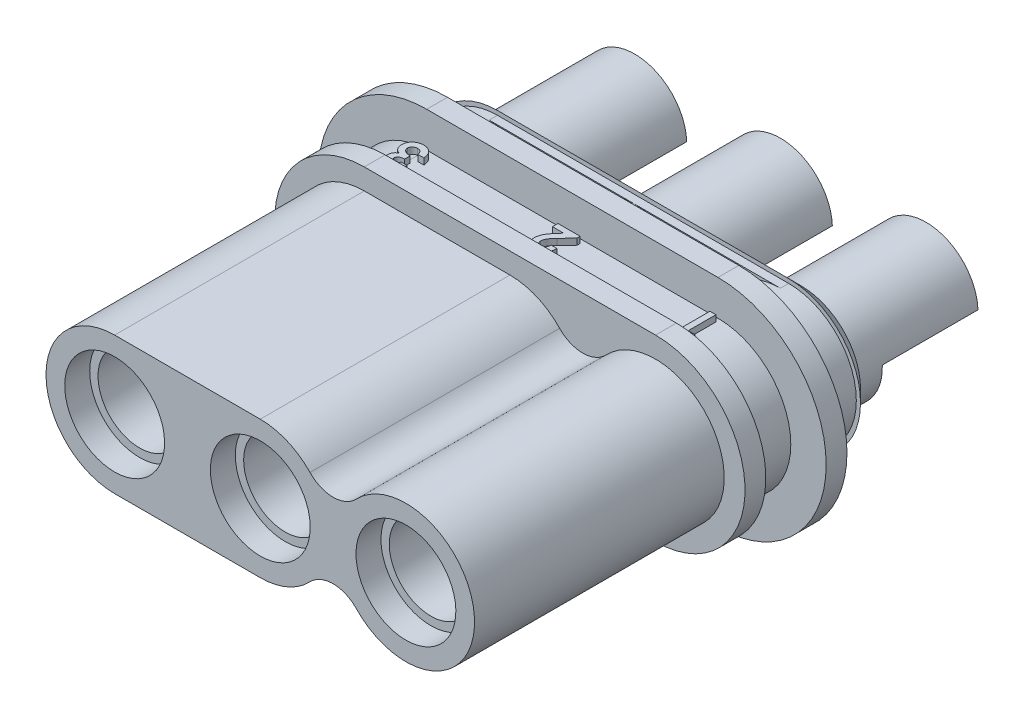
from build123d import *

# Parameters (mm, degrees)
BOSS_EXTRUDE1_DEPTH      = 6
CUT_EXTRUDE7_DEPTH       = 7
BOSS_EXTRUDE14_DEPTH     = 0.5
BOSS_EXTRUDE15_DEPTH     = 1
BOSS_EXTRUDE16_DEPTH     = 0.5
BOSS_EXTRUDE17_DEPTH     = 1.5
CHAMFER2_SIZE            = 0.3
CUT_EXTRUDE9_DEPTH       = 1.2
CUT_EXTRUDE11_DEPTH      = 1
MIRROR5_COPY_1_DEPTH     = 1
LPATTERN4_COUNT          = 3
LPATTERN4_PITCH          = 3.5
SKETCH33_W               = 2.3
SKETCH33_H               = 1.3
CUT_EXTRUDE10_DEPTH      = 7.1
CUT_EXTRUDE10_DEPTH_BACK = 7.1
LPATTERN5_COUNT          = 3
LPATTERN5_PITCH          = 3.5
BOSS_EXTRUDE18_DEPTH     = 0.3
BOSS_EXTRUDE19_DEPTH     = 0.3


with BuildPart() as part:
    # Sketch1 → Boss-Extrude1 (new body)
    with BuildSketch(Plane.XY):
        with BuildLine():
            Line((-3.5, 1.65), (3.5, 1.65))
            ThreePointArc((3.5, 1.65), (5.15, 0), (3.5, -1.65))
            Line((3.5, -1.65), (-3.5, -1.65))
            ThreePointArc((-3.5, -1.65), (-5.15, 0), (-3.5, 1.65))
        make_face()
    extrude(amount=BOSS_EXTRUDE1_DEPTH)

    # Sketch3 → Cut-Extrude7 (cut, through all)
    with BuildSketch(Plane.XY.offset(6)):
        with BuildLine():
            Line((3.5, 1.65), (0, 1.65))
            ThreePointArc((0, 1.65), (0.649966843, 1.5165893), (1.194827586, 1.137931034))
            ThreePointArc((1.194827586, 1.137931034), (1.75, 0.9), (2.305172414, 1.137931034))
            ThreePointArc((2.305172414, 1.137931034), (2.850033157, 1.5165893), (3.5, 1.65))
        make_face()
        with BuildLine():
            Line((3.5, -1.65), (0, -1.65))
            ThreePointArc((0, -1.65), (0.649966843, -1.5165893), (1.194827586, -1.137931034))
            ThreePointArc((1.194827586, -1.137931034), (1.75, -0.9), (2.305172414, -1.137931034))
            ThreePointArc((2.305172414, -1.137931034), (2.850033157, -1.5165893), (3.5, -1.65))
        make_face()
    extrude(amount=-CUT_EXTRUDE7_DEPTH, mode=Mode.SUBTRACT)

    # Sketch25 → Boss-Extrude14 (add)
    with BuildSketch(Plane(origin=(0, 0, 0), x_dir=(-1, 0, 0), z_dir=(0, 0, -1))):
        with BuildLine():
            Line((-3.5, 2.15), (3.5, 2.15))
            ThreePointArc((3.5, 2.15), (5.65, 0), (3.5, -2.15))
            Line((3.5, -2.15), (-3.5, -2.15))
            ThreePointArc((-3.5, -2.15), (-5.65, 0), (-3.5, 2.15))
        make_face()
    extrude(amount=BOSS_EXTRUDE14_DEPTH)

    # Sketch26 → Boss-Extrude15 (add)
    with BuildSketch(Plane(origin=(0, 0, -0.5), x_dir=(-1, 0, 0), z_dir=(0, 0, -1))):
        with BuildLine():
            Line((-3.5, 1.75), (3.5, 1.75))
            ThreePointArc((3.5, 1.75), (5.25, 0), (3.5, -1.75))
            Line((3.5, -1.75), (-3.5, -1.75))
            ThreePointArc((-3.5, -1.75), (-5.25, 0), (-3.5, 1.75))
        make_face()
    extrude(amount=BOSS_EXTRUDE15_DEPTH)

    # Sketch27 → Boss-Extrude16 (add)
    with BuildSketch(Plane(origin=(0, 0, -1.5), x_dir=(-1, 0, 0), z_dir=(0, 0, -1))):
        with BuildLine():
            Line((-3.5, 2.6), (3.5, 2.6))
            ThreePointArc((3.5, 2.6), (6.1, 0), (3.5, -2.6))
            Line((3.5, -2.6), (-3.5, -2.6))
            ThreePointArc((-3.5, -2.6), (-6.1, 0), (-3.5, 2.6))
        make_face()
    extrude(amount=BOSS_EXTRUDE16_DEPTH)

    # Sketch28 → Boss-Extrude17 (add)
    with BuildSketch(Plane(origin=(0, 0, -2), x_dir=(-1, 0, 0), z_dir=(0, 0, -1))):
        with BuildLine():
            Line((-3.5, 1.725), (3.5, 1.725))
            ThreePointArc((3.5, 1.725), (5.225, 0), (3.5, -1.725))
            Line((3.5, -1.725), (-3.5, -1.725))
            ThreePointArc((-3.5, -1.725), (-5.225, 0), (-3.5, 1.725))
        make_face()
    extrude(amount=BOSS_EXTRUDE17_DEPTH)

    # Chamfer2
    chamfer2_edges = [part.edges().sort_by_distance(p)[0] for p in [
        (5.225, 0, -3.5),
        (0, -1.725, -3.5),
        (-5.225, 0, -3.5),
        (0, 1.725, -3.5),
    ]]
    chamfer(chamfer2_edges, length=CHAMFER2_SIZE)

    # Sketch29 → Cut-Extrude9 (cut)
    with BuildSketch(Plane(origin=(0, 0, -2), x_dir=(-1, 0, 0), z_dir=(0, 0, -1))):
        with BuildLine():
            Line((3.5, 1.725), (-3.5, 1.725))
            ThreePointArc((-3.5, 1.725), (-5.225, 0), (-3.5, -1.725))
            Line((-3.5, -1.725), (3.5, -1.725))
            ThreePointArc((3.5, -1.725), (5.225, 0), (3.5, 1.725))
        make_face()
        with BuildLine():
            Line((3.5, 1.625), (-3.5, 1.625))
            ThreePointArc((-3.5, 1.625), (-5.125, 0), (-3.5, -1.625))
            Line((-3.5, -1.625), (3.5, -1.625))
            ThreePointArc((3.5, -1.625), (5.125, 0), (3.5, 1.625))
        make_face(mode=Mode.SUBTRACT)
    extrude(amount=CUT_EXTRUDE9_DEPTH, mode=Mode.SUBTRACT)

    # Sketch35 → Cut-Extrude11 (cut)
    with BuildSketch(Plane(origin=(0, 0, -2), x_dir=(-1, 0, 0), z_dir=(0, 0, -1))):
        with BuildLine():
            Line((3.5, 1.625), (3.5, 2.6))
            Line((3.5, 2.6), (0, 2.6))
            Line((0, 2.6), (0, 1.625))
            ThreePointArc((0, 1.625), (0.692931252, 1.46985417), (1.253548172, 1.034041576))
            ThreePointArc((1.253548172, 1.034041576), (1.75, 0.8), (2.246451828, 1.034041576))
            ThreePointArc((2.246451828, 1.034041576), (2.807068748, 1.46985417), (3.5, 1.625))
        make_face()
    cut_extrude11 = extrude(amount=CUT_EXTRUDE11_DEPTH, mode=Mode.SUBTRACT)

    # Mirror4: Cut-Extrude11 across plane
    add(cut_extrude11.mirror(Plane(origin=(0, 0, 0), x_dir=(0, 0, 1), z_dir=(1, 0, 0))), mode=Mode.SUBTRACT)

    # Mirror5: Cut-Extrude11 across plane
    add(cut_extrude11.mirror(Plane.ZX), mode=Mode.SUBTRACT)

    # Mirror5 copy 1 sketch → Mirror5 copy 1 (cut)
    with BuildSketch(Plane(origin=(0, 0, -2), x_dir=(1, 0, 0), z_dir=(0, 0, -1))):
        with BuildLine():
            Line((3.5, 1.625), (3.5, 2.6))
            Line((3.5, 2.6), (0, 2.6))
            Line((0, 2.6), (0, 1.625))
            ThreePointArc((0, 1.625), (0.692931252, 1.46985417), (1.253548172, 1.034041576))
            ThreePointArc((1.253548172, 1.034041576), (1.75, 0.8), (2.246451828, 1.034041576))
            ThreePointArc((2.246451828, 1.034041576), (2.807068748, 1.46985417), (3.5, 1.625))
        make_face()
    extrude(amount=MIRROR5_COPY_1_DEPTH, mode=Mode.SUBTRACT)

    # Sketch31 → Cut-Revolve1 (revolve, cut)
    with BuildSketch(Plane(origin=(3.5, 0, 0), x_dir=(0, 0, -1), z_dir=(1, 0, 0))):
        Polygon((-6, 0), (-6, 1.2), (0.5, 1.2), (0.5, 1.25), (3.5, 1.25), (3.5, 0), align=None)
    cut_revolve1 = revolve(axis=Axis((3.5, 0, 6), (0, 0, -1)), mode=Mode.SUBTRACT)

    # LPattern4: Cut-Revolve1 ×3
    with Locations(*[(-i * LPATTERN4_PITCH, 0, 0) for i in range(1, LPATTERN4_COUNT)]):
        add(cut_revolve1, mode=Mode.SUBTRACT)

    # Sketch38 → Boss-Extrude18 (add)
    with BuildSketch(Plane(origin=(0, 1.9, 0), x_dir=(1, 0, 0), z_dir=(0, 1, 0))):
        Polygon((3.629647436, 0.6), (3.407692308, 0.6), (3.407692308, 1.4), (3.551282051, 1.4), (3.551282051, 0.733333333), (3.715384615, 0.733333333), align=None)
        with BuildLine():
            Line((0.123076923, 0.866666667), (0.266666667, 0.866666667))
            add(Edge.make_bspline(
                [(0.266666667, 0.866666667), (0.266046768, 0.855804749), (0.264835523, 0.834581213), (0.260012214, 0.803755254), (0.253565751, 0.774620985), (0.244888653, 0.747265996), (0.234200861, 0.721678794), (0.221236367, 0.697944135), (0.206382245, 0.675891949), (0.189339082, 0.655908987), (0.170798578, 0.637943697), (0.150808265, 0.622237969), (0.129424927, 0.609090221), (0.10679155, 0.598305063), (0.082997035, 0.589675548), (0.057800973, 0.583909056), (0.031425685, 0.580003086), (0.013369504, 0.579661353), (0.004166667, 0.579487179)],
                knots=[0, 0, 0, 0, 3.2621e-05, 6.3739e-05, 9.348e-05, 0.000122065, 0.000149716, 0.000176536, 0.000203072, 0.000229337, 0.000255178, 0.000280407, 0.000305447, 0.000330319, 0.000355512, 0.000381206, 0.000407745, 0.000435332, 0.000435332, 0.000435332, 0.000435332], degree=3))
            add(Edge.make_bspline(
                [(0.004166667, 0.579487179), (-0.00713451, 0.579816538), (-0.029206749, 0.580459807), (-0.061177039, 0.586653296), (-0.091225249, 0.596193698), (-0.119054441, 0.60991552), (-0.144518759, 0.627297778), (-0.167315487, 0.648245635), (-0.187549249, 0.672502137), (-0.204553009, 0.699889992), (-0.218383227, 0.728992028), (-0.22836896, 0.758908731), (-0.234854856, 0.789036897), (-0.235551403, 0.809316467), (-0.235897436, 0.819391026)],
                knots=[0, 0, 0, 0, 3.3869e-05, 6.6149e-05, 9.7316e-05, 0.000128207, 0.000158877, 0.000189503, 0.000220794, 0.000253342, 0.000285959, 0.000317227, 0.000347807, 0.000377997, 0.000377997, 0.000377997, 0.000377997], degree=3))
            add(Edge.make_bspline(
                [(-0.235897436, 0.819391026), (-0.235763219, 0.825485184), (-0.235493074, 0.837751219), (-0.23361472, 0.85631274), (-0.230796817, 0.87521982), (-0.226548105, 0.894456247), (-0.221249619, 0.914027416), (-0.214821768, 0.933991881), (-0.20711555, 0.954236517), (-0.198259186, 0.974988912), (-0.187694797, 0.99631749), (-0.175388785, 1.018537648), (-0.161001588, 1.041710528), (-0.144673668, 1.065763984), (-0.126520041, 1.090884558), (-0.106264392, 1.116774734), (-0.084166144, 1.14372681), (-0.068477229, 1.161739256), (-0.060416667, 1.17099359)],
                knots=[0, 0, 0, 0, 1.828e-05, 3.6794e-05, 5.5923e-05, 7.56e-05, 9.5854e-05, 0.000116734, 0.000138492, 0.000160818, 0.000184398, 0.000209863, 0.000236992, 0.000266194, 0.000297064, 0.000329953, 0.000364795, 0.000401611, 0.000401611, 0.000401611, 0.000401611], degree=3))
            Line((-0.060416667, 1.17099359), (0.023076923, 1.266666667))
            Line((0.023076923, 1.266666667), (-0.246153846, 1.266666667))
            Line((-0.246153846, 1.266666667), (-0.246153846, 1.4))
            Line((-0.246153846, 1.4), (0.287179487, 1.4))
            Line((0.287179487, 1.4), (0.287179487, 1.32724359))
            Line((0.287179487, 1.32724359), (0.050320513, 1.075160256))
            add(Edge.make_bspline(
                [(0.050320513, 1.075160256), (0.043462728, 1.06780698), (0.030181233, 1.053565866), (0.011284798, 1.032650078), (-0.005821099, 1.01280578), (-0.020753974, 0.993802842), (-0.034417307, 0.97628468), (-0.045847691, 0.959589039), (-0.055802154, 0.944186098), (-0.066200643, 0.925410527), (-0.07630305, 0.903186446), (-0.085566796, 0.877599219), (-0.091157085, 0.853126573), (-0.091934663, 0.837151121), (-0.092307692, 0.829487179)],
                knots=[0, 0, 0, 0, 3.0164e-05, 5.8419e-05, 8.4562e-05, 0.000108739, 0.000130919, 0.00015119, 0.000169418, 0.000185917, 0.000215533, 0.000242548, 0.000267475, 0.000290459, 0.000290459, 0.000290459, 0.000290459], degree=3))
            add(Edge.make_bspline(
                [(-0.092307692, 0.829487179), (-0.092033867, 0.822070436), (-0.091503287, 0.807699307), (-0.085527303, 0.787315926), (-0.076585755, 0.768720806), (-0.063604322, 0.752761006), (-0.047936064, 0.739531817), (-0.029726945, 0.729837626), (-0.009311298, 0.724139891), (0.004985166, 0.723437999), (0.012339744, 0.723076923)],
                knots=[0, 0, 0, 0, 2.2186e-05, 4.2988e-05, 6.3199e-05, 8.3722e-05, 0.000104199, 0.000124345, 0.000145147, 0.000167186, 0.000167186, 0.000167186, 0.000167186], degree=3))
            add(Edge.make_bspline(
                [(0.012339744, 0.723076923), (0.016138463, 0.723211282), (0.023616852, 0.723475789), (0.034609499, 0.72523654), (0.045069793, 0.728339679), (0.055114162, 0.73249745), (0.06463541, 0.738008604), (0.073609521, 0.74480198), (0.08213105, 0.752704942), (0.090160913, 0.761692779), (0.097469136, 0.771723208), (0.103960273, 0.78270462), (0.109327363, 0.794630201), (0.114052744, 0.807342514), (0.117697184, 0.820978099), (0.120350788, 0.835455349), (0.122368146, 0.850750712), (0.122836366, 0.861264835), (0.123076923, 0.866666667)],
                knots=[0, 0, 0, 0, 1.1396e-05, 2.2435e-05, 3.3288e-05, 4.4062e-05, 5.4975e-05, 6.6193e-05, 7.776e-05, 8.9791e-05, 0.000102292, 0.000114935, 0.000127986, 0.000141472, 0.000155584, 0.000170262, 0.000185607, 0.000201822, 0.000201822, 0.000201822, 0.000201822], degree=3))
        make_face()
        with BuildLine():
            Line((-3.407692308, 0.794871795), (-3.264102564, 0.794871795))
            add(Edge.make_bspline(
                [(-3.264102564, 0.794871795), (-3.265110038, 0.787692685), (-3.267077884, 0.773670107), (-3.27191539, 0.753320344), (-3.277509672, 0.73396922), (-3.284663968, 0.715720587), (-3.292922312, 0.698594117), (-3.302552662, 0.682574484), (-3.313108163, 0.667431794), (-3.321372461, 0.658357249), (-3.325480769, 0.653846154)],
                knots=[0, 0, 0, 0, 2.1736e-05, 4.2457e-05, 6.2688e-05, 8.2121e-05, 0.000101186, 0.000119655, 0.000138154, 0.000156441, 0.000156441, 0.000156441, 0.000156441], degree=3))
            add(Edge.make_bspline(
                [(-3.325480769, 0.653846154), (-3.331391845, 0.647884889), (-3.343041954, 0.636135864), (-3.362510653, 0.621086659), (-3.382917445, 0.608062597), (-3.404671597, 0.597737025), (-3.427434599, 0.589379672), (-3.451387468, 0.583766018), (-3.476432326, 0.58004131), (-3.493522291, 0.579674413), (-3.50224359, 0.579487179)],
                knots=[0, 0, 0, 0, 2.5161e-05, 4.9589e-05, 7.3643e-05, 9.7655e-05, 0.000121684, 0.000146249, 0.000171338, 0.000197484, 0.000197484, 0.000197484, 0.000197484], degree=3))
            add(Edge.make_bspline(
                [(-3.50224359, 0.579487179), (-3.509997273, 0.579670229), (-3.525239452, 0.580030067), (-3.54764162, 0.582918651), (-3.569000212, 0.587984905), (-3.589540995, 0.59460892), (-3.608961881, 0.603621998), (-3.627691508, 0.614084264), (-3.645206569, 0.626916668), (-3.661548047, 0.641415992), (-3.676560811, 0.657098432), (-3.68956193, 0.673861669), (-3.700739225, 0.691257921), (-3.709947838, 0.709431716), (-3.717028011, 0.728413808), (-3.72194186, 0.748094539), (-3.725158094, 0.768430481), (-3.725478515, 0.782252548), (-3.725641026, 0.789262821)],
                knots=[0, 0, 0, 0, 2.3257e-05, 4.5719e-05, 6.7604e-05, 8.9041e-05, 0.000110341, 0.000131729, 0.000153302, 0.000175328, 0.000197206, 0.000218331, 0.00023887, 0.000259152, 0.000279334, 0.000299507, 0.000319928, 0.000340943, 0.000340943, 0.000340943, 0.000340943], degree=3))
            add(Edge.make_bspline(
                [(-3.725641026, 0.789262821), (-3.725301122, 0.797942918), (-3.724629907, 0.815083709), (-3.719321582, 0.840121172), (-3.710788146, 0.86400708), (-3.698654865, 0.886458422), (-3.683418114, 0.907451808), (-3.664733127, 0.926254035), (-3.643121327, 0.943156287), (-3.626897512, 0.952239674), (-3.618589744, 0.956891026)],
                knots=[0, 0, 0, 0, 2.6021e-05, 5.1385e-05, 7.6427e-05, 0.00010188, 0.000127683, 0.000153974, 0.000181157, 0.000209685, 0.000209685, 0.000209685, 0.000209685], degree=3))
            add(Edge.make_bspline(
                [(-3.618589744, 0.956891026), (-3.624292282, 0.95876298), (-3.635497514, 0.962441288), (-3.651421192, 0.969690146), (-3.666575254, 0.977595115), (-3.680613131, 0.98682332), (-3.693919779, 0.996735132), (-3.706074192, 1.007863481), (-3.717391107, 1.019922719), (-3.727590556, 1.033041134), (-3.736709336, 1.047000613), (-3.744745628, 1.061550257), (-3.751489587, 1.076743241), (-3.757149758, 1.092467918), (-3.761468312, 1.108879044), (-3.764506571, 1.125921006), (-3.766263332, 1.143552739), (-3.766531215, 1.15549831), (-3.766666667, 1.161538462)],
                knots=[0, 0, 0, 0, 1.7992e-05, 3.5354e-05, 5.2417e-05, 6.9219e-05, 8.5694e-05, 0.000102144, 0.000118585, 0.000135255, 0.000151923, 0.000168563, 0.000185062, 0.000201739, 0.000218648, 0.000235906, 0.000253622, 0.000271742, 0.000271742, 0.000271742, 0.000271742], degree=3))
            add(Edge.make_bspline(
                [(-3.766666667, 1.161538462), (-3.766415585, 1.170418926), (-3.765920292, 1.187936833), (-3.762139581, 1.213654894), (-3.756067127, 1.238306774), (-3.747535492, 1.261923544), (-3.736364904, 1.284434281), (-3.722873121, 1.305990358), (-3.706895308, 1.326422392), (-3.688673719, 1.345549362), (-3.668607444, 1.363102462), (-3.646991124, 1.378595763), (-3.623811188, 1.391371324), (-3.599620552, 1.402290041), (-3.573876266, 1.410393698), (-3.546910808, 1.416328048), (-3.518527417, 1.419938703), (-3.499155961, 1.420318735), (-3.489262821, 1.420512821)],
                knots=[0, 0, 0, 0, 2.6633e-05, 5.2538e-05, 7.7802e-05, 0.000102694, 0.000127706, 0.000153051, 0.000178857, 0.000205382, 0.000232187, 0.000258734, 0.000284993, 0.000311467, 0.000338226, 0.000365794, 0.000394219, 0.000423888, 0.000423888, 0.000423888, 0.000423888], degree=3))
            add(Edge.make_bspline(
                [(-3.489262821, 1.420512821), (-3.47990384, 1.420308711), (-3.461603591, 1.419909602), (-3.434836164, 1.416453481), (-3.4093943, 1.410882333), (-3.385222195, 1.403015976), (-3.362422759, 1.392881034), (-3.340863165, 1.38064799), (-3.320778775, 1.365942023), (-3.302077124, 1.349110101), (-3.284916761, 1.330485787), (-3.269960833, 1.309917271), (-3.256945234, 1.287853995), (-3.245784062, 1.26424851), (-3.237063597, 1.238890193), (-3.230128443, 1.212005501), (-3.225300187, 1.183478185), (-3.223827688, 1.163852473), (-3.223076923, 1.153846154)],
                knots=[0, 0, 0, 0, 2.8067e-05, 5.4882e-05, 8.0816e-05, 0.000106105, 0.000131, 0.000155549, 0.000180327, 0.00020552, 0.000230929, 0.000256155, 0.00028166, 0.000307684, 0.000334344, 0.000361979, 0.000390907, 0.000420999, 0.000420999, 0.000420999, 0.000420999], degree=3))
            Line((-3.223076923, 1.153846154), (-3.366666667, 1.153846154))
            add(Edge.make_bspline(
                [(-3.366666667, 1.153846154), (-3.367576757, 1.158877451), (-3.369349398, 1.168677223), (-3.372803698, 1.182866509), (-3.377316971, 1.195958941), (-3.382476982, 1.208050709), (-3.38818198, 1.219265904), (-3.394998463, 1.229304614), (-3.402307246, 1.238561359), (-3.413294012, 1.249201364), (-3.428623067, 1.260359659), (-3.449377705, 1.270241956), (-3.472570598, 1.27586239), (-3.488751847, 1.276561652), (-3.497115385, 1.276923077)],
                knots=[0, 0, 0, 0, 1.5338e-05, 2.9874e-05, 4.376e-05, 5.6828e-05, 6.93e-05, 8.1434e-05, 9.3172e-05, 0.000104618, 0.000127217, 0.000149726, 0.000173164, 0.000198237, 0.000198237, 0.000198237, 0.000198237], degree=3))
            add(Edge.make_bspline(
                [(-3.497115385, 1.276923077), (-3.501554056, 1.276846697), (-3.510248421, 1.276697087), (-3.523021245, 1.27504823), (-3.535181139, 1.272312985), (-3.54685512, 1.268641539), (-3.557883958, 1.263800065), (-3.568408651, 1.258042591), (-3.578241926, 1.251043346), (-3.587414758, 1.243150693), (-3.595716249, 1.234459495), (-3.603224491, 1.225380966), (-3.609250591, 1.215544148), (-3.614252745, 1.205338059), (-3.61837892, 1.194765335), (-3.620967673, 1.183585416), (-3.622905828, 1.172022385), (-3.623019322, 1.164111229), (-3.623076923, 1.160096154)],
                knots=[0, 0, 0, 0, 1.331e-05, 2.6071e-05, 3.8552e-05, 5.0665e-05, 6.2722e-05, 7.463e-05, 8.659e-05, 9.8862e-05, 0.000110876, 0.000122614, 0.000134131, 0.000145384, 0.000156694, 0.000168082, 0.000179755, 0.000191783, 0.000191783, 0.000191783, 0.000191783], degree=3))
            add(Edge.make_bspline(
                [(-3.623076923, 1.160096154), (-3.62293067, 1.155703491), (-3.622641263, 1.14701125), (-3.620094498, 1.134273186), (-3.616282366, 1.121972746), (-3.610799812, 1.110211417), (-3.603625646, 1.099058371), (-3.594902596, 1.088421236), (-3.584551752, 1.078384702), (-3.572919734, 1.068656464), (-3.559537212, 1.06014041), (-3.544944592, 1.052298399), (-3.528782374, 1.046054224), (-3.511438291, 1.040478382), (-3.492586234, 1.036405534), (-3.472342699, 1.033448348), (-3.450740506, 1.031247152), (-3.435849827, 1.030931356), (-3.428205128, 1.030769231)],
                knots=[0, 0, 0, 0, 1.3165e-05, 2.6052e-05, 3.8824e-05, 5.173e-05, 6.4844e-05, 7.851e-05, 9.2902e-05, 0.000108045, 0.000123914, 0.000140402, 0.000157662, 0.000175807, 0.000195014, 0.000215435, 0.00023717, 0.0002601, 0.0002601, 0.0002601, 0.0002601], degree=3))
            Line((-3.428205128, 1.030769231), (-3.428205128, 0.897435897))
            add(Edge.make_bspline(
                [(-3.428205128, 0.897435897), (-3.437724188, 0.89662759), (-3.455532462, 0.895115408), (-3.480237317, 0.891541593), (-3.501146182, 0.886868989), (-3.518483817, 0.88088338), (-3.533095555, 0.873858931), (-3.545535092, 0.865525082), (-3.556609378, 0.856297296), (-3.565650741, 0.84569821), (-3.572956996, 0.834509718), (-3.578130362, 0.822762631), (-3.581564502, 0.810718096), (-3.581889998, 0.802479613), (-3.582051282, 0.798397436)],
                knots=[0, 0, 0, 0, 2.8655e-05, 5.3609e-05, 7.4833e-05, 9.2826e-05, 0.000108522, 0.000123323, 0.000137646, 0.000151621, 0.000164957, 0.000177584, 0.000190023, 0.000202241, 0.000202241, 0.000202241, 0.000202241], degree=3))
            add(Edge.make_bspline(
                [(-3.582051282, 0.798397436), (-3.581779439, 0.793185696), (-3.58124886, 0.783013483), (-3.576936579, 0.768490819), (-3.569930338, 0.755330384), (-3.560065735, 0.743985882), (-3.54799617, 0.734619235), (-3.533935683, 0.727792187), (-3.518122667, 0.723708571), (-3.507022724, 0.723292241), (-3.501282051, 0.723076923)],
                knots=[0, 0, 0, 0, 1.5612e-05, 3.0471e-05, 4.5026e-05, 6.0027e-05, 7.5221e-05, 9.0558e-05, 0.000106611, 0.000123807, 0.000123807, 0.000123807, 0.000123807], degree=3))
            add(Edge.make_bspline(
                [(-3.501282051, 0.723076923), (-3.49607903, 0.723332439), (-3.485754643, 0.723839461), (-3.470663393, 0.727640582), (-3.456348242, 0.733974611), (-3.443176315, 0.742869387), (-3.431180006, 0.753441906), (-3.421121344, 0.765862082), (-3.412932971, 0.779644117), (-3.409446044, 0.789776003), (-3.407692308, 0.794871795)],
                knots=[0, 0, 0, 0, 1.5598e-05, 3.0951e-05, 4.6376e-05, 6.2333e-05, 7.8449e-05, 9.4167e-05, 0.00011011, 0.000126241, 0.000126241, 0.000126241, 0.000126241], degree=3))
        make_face()
    extrude(amount=-BOSS_EXTRUDE18_DEPTH)

    # Sketch39 → Boss-Extrude19 (add)
    with BuildSketch(Plane(origin=(0, -1.9, 0), x_dir=(-1, 0, 0), z_dir=(0, -1, 0))):
        with BuildLine():
            Line((3.592307692, 0.794871795), (3.735897436, 0.794871795))
            add(Edge.make_bspline(
                [(3.735897436, 0.794871795), (3.734889962, 0.787692685), (3.732922116, 0.773670107), (3.72808461, 0.753320344), (3.722490328, 0.73396922), (3.715336032, 0.715720587), (3.707077688, 0.698594117), (3.697447338, 0.682574484), (3.686891837, 0.667431794), (3.678627539, 0.658357249), (3.674519231, 0.653846154)],
                knots=[0, 0, 0, 0, 2.1736e-05, 4.2457e-05, 6.2688e-05, 8.2121e-05, 0.000101186, 0.000119655, 0.000138154, 0.000156441, 0.000156441, 0.000156441, 0.000156441], degree=3))
            add(Edge.make_bspline(
                [(3.674519231, 0.653846154), (3.668608155, 0.647884889), (3.656958046, 0.636135864), (3.637489347, 0.621086659), (3.617082555, 0.608062597), (3.595328403, 0.597737025), (3.572565401, 0.589379672), (3.548612532, 0.583766018), (3.523567674, 0.58004131), (3.506477709, 0.579674413), (3.49775641, 0.579487179)],
                knots=[0, 0, 0, 0, 2.5161e-05, 4.9589e-05, 7.3643e-05, 9.7655e-05, 0.000121684, 0.000146249, 0.000171338, 0.000197484, 0.000197484, 0.000197484, 0.000197484], degree=3))
            add(Edge.make_bspline(
                [(3.49775641, 0.579487179), (3.490002727, 0.579670229), (3.474760548, 0.580030067), (3.45235838, 0.582918651), (3.430999788, 0.587984905), (3.410459005, 0.59460892), (3.391038119, 0.603621998), (3.372308492, 0.614084264), (3.354793431, 0.626916668), (3.338451953, 0.641415992), (3.323439189, 0.657098432), (3.31043807, 0.673861669), (3.299260775, 0.691257921), (3.290052162, 0.709431716), (3.282971989, 0.728413808), (3.27805814, 0.748094539), (3.274841906, 0.768430481), (3.274521485, 0.782252548), (3.274358974, 0.789262821)],
                knots=[0, 0, 0, 0, 2.3257e-05, 4.5719e-05, 6.7604e-05, 8.9041e-05, 0.000110341, 0.000131729, 0.000153302, 0.000175328, 0.000197206, 0.000218331, 0.00023887, 0.000259152, 0.000279334, 0.000299507, 0.000319928, 0.000340943, 0.000340943, 0.000340943, 0.000340943], degree=3))
            add(Edge.make_bspline(
                [(3.274358974, 0.789262821), (3.274698878, 0.797942918), (3.275370093, 0.815083709), (3.280678418, 0.840121172), (3.289211854, 0.86400708), (3.301345135, 0.886458422), (3.316581886, 0.907451808), (3.335266873, 0.926254035), (3.356878673, 0.943156287), (3.373102488, 0.952239674), (3.381410256, 0.956891026)],
                knots=[0, 0, 0, 0, 2.6021e-05, 5.1385e-05, 7.6427e-05, 0.00010188, 0.000127683, 0.000153974, 0.000181157, 0.000209685, 0.000209685, 0.000209685, 0.000209685], degree=3))
            add(Edge.make_bspline(
                [(3.381410256, 0.956891026), (3.375707718, 0.95876298), (3.364502486, 0.962441288), (3.348578808, 0.969690146), (3.333424746, 0.977595115), (3.319386869, 0.98682332), (3.306080221, 0.996735132), (3.293925808, 1.007863481), (3.282608893, 1.019922719), (3.272409444, 1.033041134), (3.263290664, 1.047000613), (3.255254372, 1.061550257), (3.248510413, 1.076743241), (3.242850242, 1.092467918), (3.238531688, 1.108879044), (3.235493429, 1.125921006), (3.233736668, 1.143552739), (3.233468785, 1.15549831), (3.233333333, 1.161538462)],
                knots=[0, 0, 0, 0, 1.7992e-05, 3.5354e-05, 5.2417e-05, 6.9219e-05, 8.5694e-05, 0.000102144, 0.000118585, 0.000135255, 0.000151923, 0.000168563, 0.000185062, 0.000201739, 0.000218648, 0.000235906, 0.000253622, 0.000271742, 0.000271742, 0.000271742, 0.000271742], degree=3))
            add(Edge.make_bspline(
                [(3.233333333, 1.161538462), (3.233584415, 1.170418926), (3.234079708, 1.187936833), (3.237860419, 1.213654894), (3.243932873, 1.238306774), (3.252464508, 1.261923544), (3.263635096, 1.284434281), (3.277126879, 1.305990358), (3.293104692, 1.326422392), (3.311326281, 1.345549362), (3.331392556, 1.363102462), (3.353008876, 1.378595763), (3.376188812, 1.391371324), (3.400379448, 1.402290041), (3.426123734, 1.410393698), (3.453089192, 1.416328048), (3.481472583, 1.419938703), (3.500844039, 1.420318735), (3.510737179, 1.420512821)],
                knots=[0, 0, 0, 0, 2.6633e-05, 5.2538e-05, 7.7802e-05, 0.000102694, 0.000127706, 0.000153051, 0.000178857, 0.000205382, 0.000232187, 0.000258734, 0.000284993, 0.000311467, 0.000338226, 0.000365794, 0.000394219, 0.000423888, 0.000423888, 0.000423888, 0.000423888], degree=3))
            add(Edge.make_bspline(
                [(3.510737179, 1.420512821), (3.52009616, 1.420308711), (3.538396409, 1.419909602), (3.565163836, 1.416453481), (3.5906057, 1.410882333), (3.614777805, 1.403015976), (3.637577241, 1.392881034), (3.659136835, 1.38064799), (3.679221225, 1.365942023), (3.697922876, 1.349110101), (3.715083239, 1.330485787), (3.730039167, 1.309917271), (3.743054766, 1.287853995), (3.754215938, 1.26424851), (3.762936403, 1.238890193), (3.769871557, 1.212005501), (3.774699813, 1.183478185), (3.776172312, 1.163852473), (3.776923077, 1.153846154)],
                knots=[0, 0, 0, 0, 2.8067e-05, 5.4882e-05, 8.0816e-05, 0.000106105, 0.000131, 0.000155549, 0.000180327, 0.00020552, 0.000230929, 0.000256155, 0.00028166, 0.000307684, 0.000334344, 0.000361979, 0.000390907, 0.000420999, 0.000420999, 0.000420999, 0.000420999], degree=3))
            Line((3.776923077, 1.153846154), (3.633333333, 1.153846154))
            add(Edge.make_bspline(
                [(3.633333333, 1.153846154), (3.632423243, 1.158877451), (3.630650602, 1.168677223), (3.627196302, 1.182866509), (3.622683029, 1.195958941), (3.617523018, 1.208050709), (3.61181802, 1.219265904), (3.605001537, 1.229304614), (3.597692754, 1.238561359), (3.586705988, 1.249201364), (3.571376933, 1.260359659), (3.550622295, 1.270241956), (3.527429402, 1.27586239), (3.511248153, 1.276561652), (3.502884615, 1.276923077)],
                knots=[0, 0, 0, 0, 1.5338e-05, 2.9874e-05, 4.376e-05, 5.6828e-05, 6.93e-05, 8.1434e-05, 9.3172e-05, 0.000104618, 0.000127217, 0.000149726, 0.000173164, 0.000198237, 0.000198237, 0.000198237, 0.000198237], degree=3))
            add(Edge.make_bspline(
                [(3.502884615, 1.276923077), (3.498445944, 1.276846697), (3.489751579, 1.276697087), (3.476978755, 1.27504823), (3.464818861, 1.272312985), (3.45314488, 1.268641539), (3.442116042, 1.263800065), (3.431591349, 1.258042591), (3.421758074, 1.251043346), (3.412585242, 1.243150693), (3.404283751, 1.234459495), (3.396775509, 1.225380966), (3.390749409, 1.215544148), (3.385747255, 1.205338059), (3.38162108, 1.194765335), (3.379032327, 1.183585416), (3.377094172, 1.172022385), (3.376980678, 1.164111229), (3.376923077, 1.160096154)],
                knots=[0, 0, 0, 0, 1.331e-05, 2.6071e-05, 3.8552e-05, 5.0665e-05, 6.2722e-05, 7.463e-05, 8.659e-05, 9.8862e-05, 0.000110876, 0.000122614, 0.000134131, 0.000145384, 0.000156694, 0.000168082, 0.000179755, 0.000191783, 0.000191783, 0.000191783, 0.000191783], degree=3))
            add(Edge.make_bspline(
                [(3.376923077, 1.160096154), (3.37706933, 1.155703491), (3.377358737, 1.14701125), (3.379905502, 1.134273186), (3.383717634, 1.121972746), (3.389200188, 1.110211417), (3.396374354, 1.099058371), (3.405097404, 1.088421236), (3.415448248, 1.078384702), (3.427080266, 1.068656464), (3.440462788, 1.06014041), (3.455055408, 1.052298399), (3.471217626, 1.046054224), (3.488561709, 1.040478382), (3.507413766, 1.036405534), (3.527657301, 1.033448348), (3.549259494, 1.031247152), (3.564150173, 1.030931356), (3.571794872, 1.030769231)],
                knots=[0, 0, 0, 0, 1.3165e-05, 2.6052e-05, 3.8824e-05, 5.173e-05, 6.4844e-05, 7.851e-05, 9.2902e-05, 0.000108045, 0.000123914, 0.000140402, 0.000157662, 0.000175807, 0.000195014, 0.000215435, 0.00023717, 0.0002601, 0.0002601, 0.0002601, 0.0002601], degree=3))
            Line((3.571794872, 1.030769231), (3.571794872, 0.897435897))
            add(Edge.make_bspline(
                [(3.571794872, 0.897435897), (3.562275812, 0.89662759), (3.544467538, 0.895115408), (3.519762683, 0.891541593), (3.498853818, 0.886868989), (3.481516183, 0.88088338), (3.466904445, 0.873858931), (3.454464908, 0.865525082), (3.443390622, 0.856297296), (3.434349259, 0.84569821), (3.427043004, 0.834509718), (3.421869638, 0.822762631), (3.418435498, 0.810718096), (3.418110002, 0.802479613), (3.417948718, 0.798397436)],
                knots=[0, 0, 0, 0, 2.8655e-05, 5.3609e-05, 7.4833e-05, 9.2826e-05, 0.000108522, 0.000123323, 0.000137646, 0.000151621, 0.000164957, 0.000177584, 0.000190023, 0.000202241, 0.000202241, 0.000202241, 0.000202241], degree=3))
            add(Edge.make_bspline(
                [(3.417948718, 0.798397436), (3.418220561, 0.793185696), (3.41875114, 0.783013483), (3.423063421, 0.768490819), (3.430069662, 0.755330384), (3.439934265, 0.743985882), (3.45200383, 0.734619235), (3.466064317, 0.727792187), (3.481877333, 0.723708571), (3.492977276, 0.723292241), (3.498717949, 0.723076923)],
                knots=[0, 0, 0, 0, 1.5612e-05, 3.0471e-05, 4.5026e-05, 6.0027e-05, 7.5221e-05, 9.0558e-05, 0.000106611, 0.000123807, 0.000123807, 0.000123807, 0.000123807], degree=3))
            add(Edge.make_bspline(
                [(3.498717949, 0.723076923), (3.50392097, 0.723332439), (3.514245357, 0.723839461), (3.529336607, 0.727640582), (3.543651758, 0.733974611), (3.556823685, 0.742869387), (3.568819994, 0.753441906), (3.578878656, 0.765862082), (3.587067029, 0.779644117), (3.590553956, 0.789776003), (3.592307692, 0.794871795)],
                knots=[0, 0, 0, 0, 1.5598e-05, 3.0951e-05, 4.6376e-05, 6.2333e-05, 7.8449e-05, 9.4167e-05, 0.00011011, 0.000126241, 0.000126241, 0.000126241, 0.000126241], degree=3))
        make_face()
        with BuildLine():
            Line((0.123076923, 0.866666667), (0.266666667, 0.866666667))
            add(Edge.make_bspline(
                [(0.266666667, 0.866666667), (0.266046768, 0.855804749), (0.264835523, 0.834581213), (0.260012214, 0.803755254), (0.253565751, 0.774620985), (0.244888653, 0.747265996), (0.234200861, 0.721678794), (0.221236367, 0.697944135), (0.206382245, 0.675891949), (0.189339082, 0.655908987), (0.170798578, 0.637943697), (0.150808265, 0.622237969), (0.129424927, 0.609090221), (0.10679155, 0.598305063), (0.082997035, 0.589675548), (0.057800973, 0.583909056), (0.031425685, 0.580003086), (0.013369504, 0.579661353), (0.004166667, 0.579487179)],
                knots=[0, 0, 0, 0, 3.2621e-05, 6.3739e-05, 9.348e-05, 0.000122065, 0.000149716, 0.000176536, 0.000203072, 0.000229337, 0.000255178, 0.000280407, 0.000305447, 0.000330319, 0.000355512, 0.000381206, 0.000407745, 0.000435332, 0.000435332, 0.000435332, 0.000435332], degree=3))
            add(Edge.make_bspline(
                [(0.004166667, 0.579487179), (-0.00713451, 0.579816538), (-0.029206749, 0.580459807), (-0.061177039, 0.586653296), (-0.091225249, 0.596193698), (-0.119054441, 0.60991552), (-0.144518759, 0.627297778), (-0.167315487, 0.648245635), (-0.187549249, 0.672502137), (-0.204553009, 0.699889992), (-0.218383227, 0.728992028), (-0.22836896, 0.758908731), (-0.234854856, 0.789036897), (-0.235551403, 0.809316467), (-0.235897436, 0.819391026)],
                knots=[0, 0, 0, 0, 3.3869e-05, 6.6149e-05, 9.7316e-05, 0.000128207, 0.000158877, 0.000189503, 0.000220794, 0.000253342, 0.000285959, 0.000317227, 0.000347807, 0.000377997, 0.000377997, 0.000377997, 0.000377997], degree=3))
            add(Edge.make_bspline(
                [(-0.235897436, 0.819391026), (-0.235763219, 0.825485184), (-0.235493074, 0.837751219), (-0.23361472, 0.85631274), (-0.230796817, 0.87521982), (-0.226548105, 0.894456247), (-0.221249619, 0.914027416), (-0.214821768, 0.933991881), (-0.20711555, 0.954236517), (-0.198259186, 0.974988912), (-0.187694797, 0.99631749), (-0.175388785, 1.018537648), (-0.161001588, 1.041710528), (-0.144673668, 1.065763984), (-0.126520041, 1.090884558), (-0.106264392, 1.116774734), (-0.084166144, 1.14372681), (-0.068477229, 1.161739256), (-0.060416667, 1.17099359)],
                knots=[0, 0, 0, 0, 1.828e-05, 3.6794e-05, 5.5923e-05, 7.56e-05, 9.5854e-05, 0.000116734, 0.000138492, 0.000160818, 0.000184398, 0.000209863, 0.000236992, 0.000266194, 0.000297064, 0.000329953, 0.000364795, 0.000401611, 0.000401611, 0.000401611, 0.000401611], degree=3))
            Line((-0.060416667, 1.17099359), (0.023076923, 1.266666667))
            Line((0.023076923, 1.266666667), (-0.246153846, 1.266666667))
            Line((-0.246153846, 1.266666667), (-0.246153846, 1.4))
            Line((-0.246153846, 1.4), (0.287179487, 1.4))
            Line((0.287179487, 1.4), (0.287179487, 1.32724359))
            Line((0.287179487, 1.32724359), (0.050320513, 1.075160256))
            add(Edge.make_bspline(
                [(0.050320513, 1.075160256), (0.043462728, 1.06780698), (0.030181233, 1.053565866), (0.011284798, 1.032650078), (-0.005821099, 1.01280578), (-0.020753974, 0.993802842), (-0.034417307, 0.97628468), (-0.045847691, 0.959589039), (-0.055802154, 0.944186098), (-0.066200643, 0.925410527), (-0.07630305, 0.903186446), (-0.085566796, 0.877599219), (-0.091157085, 0.853126573), (-0.091934663, 0.837151121), (-0.092307692, 0.829487179)],
                knots=[0, 0, 0, 0, 3.0164e-05, 5.8419e-05, 8.4562e-05, 0.000108739, 0.000130919, 0.00015119, 0.000169418, 0.000185917, 0.000215533, 0.000242548, 0.000267475, 0.000290459, 0.000290459, 0.000290459, 0.000290459], degree=3))
            add(Edge.make_bspline(
                [(-0.092307692, 0.829487179), (-0.092033867, 0.822070436), (-0.091503287, 0.807699307), (-0.085527303, 0.787315926), (-0.076585755, 0.768720806), (-0.063604322, 0.752761006), (-0.047936064, 0.739531817), (-0.029726945, 0.729837626), (-0.009311298, 0.724139891), (0.004985166, 0.723437999), (0.012339744, 0.723076923)],
                knots=[0, 0, 0, 0, 2.2186e-05, 4.2988e-05, 6.3199e-05, 8.3722e-05, 0.000104199, 0.000124345, 0.000145147, 0.000167186, 0.000167186, 0.000167186, 0.000167186], degree=3))
            add(Edge.make_bspline(
                [(0.012339744, 0.723076923), (0.016138463, 0.723211282), (0.023616852, 0.723475789), (0.034609499, 0.72523654), (0.045069793, 0.728339679), (0.055114162, 0.73249745), (0.06463541, 0.738008604), (0.073609521, 0.74480198), (0.08213105, 0.752704942), (0.090160913, 0.761692779), (0.097469136, 0.771723208), (0.103960273, 0.78270462), (0.109327363, 0.794630201), (0.114052744, 0.807342514), (0.117697184, 0.820978099), (0.120350788, 0.835455349), (0.122368146, 0.850750712), (0.122836366, 0.861264835), (0.123076923, 0.866666667)],
                knots=[0, 0, 0, 0, 1.1396e-05, 2.2435e-05, 3.3288e-05, 4.4062e-05, 5.4975e-05, 6.6193e-05, 7.776e-05, 8.9791e-05, 0.000102292, 0.000114935, 0.000127986, 0.000141472, 0.000155584, 0.000170262, 0.000185607, 0.000201822, 0.000201822, 0.000201822, 0.000201822], degree=3))
        make_face()
        Polygon((-3.370352564, 0.6), (-3.592307692, 0.6), (-3.592307692, 1.4), (-3.448717949, 1.4), (-3.448717949, 0.733333333), (-3.284615385, 0.733333333), align=None)
    extrude(amount=-BOSS_EXTRUDE19_DEPTH)


with BuildPart() as body_2:
    # Sketch32 → Revolve1 (revolve)
    with BuildSketch(Plane(origin=(3.5, 0, 0), x_dir=(0, 0, -1), z_dir=(1, 0, 0))):
        Polygon((-5.4, 1.2), (-5.4, 1), (1.1, 1), (1.700860619, 0), (2.379397567, 0), (2.8, 0.7), (6.5, 0.7), (6.5, 1.25), (0.5, 1.25), (0.5, 1.2), align=None)
    revolve(axis=Axis((3.5, 0, 0), (0, 0, 1)))

    # Sketch33 → Cut-Extrude10 (cut, two sides)
    with BuildSketch(Plane(origin=(0, 0, 0), x_dir=(0, 0, -1), z_dir=(1, 0, 0))) as cut_extrude10_sk:
        with Locations((5.35, -0.6)):
            Rectangle(SKETCH33_W, SKETCH33_H)
    extrude(amount=CUT_EXTRUDE10_DEPTH, mode=Mode.SUBTRACT)
    extrude(cut_extrude10_sk.sketch, amount=-CUT_EXTRUDE10_DEPTH_BACK, mode=Mode.SUBTRACT)


with BuildPart() as lpattern5_1:
    # LPattern5: pattern copy
    add(body_2.part.moved(Location(Vector(-1, 0, 0) * (1 * LPATTERN5_PITCH))))


with BuildPart() as lpattern5_2:
    # LPattern5: pattern copy
    add(body_2.part.moved(Location(Vector(-1, 0, 0) * (2 * LPATTERN5_PITCH))))


solid = Compound([part.part, body_2.part, lpattern5_1.part, lpattern5_2.part])
